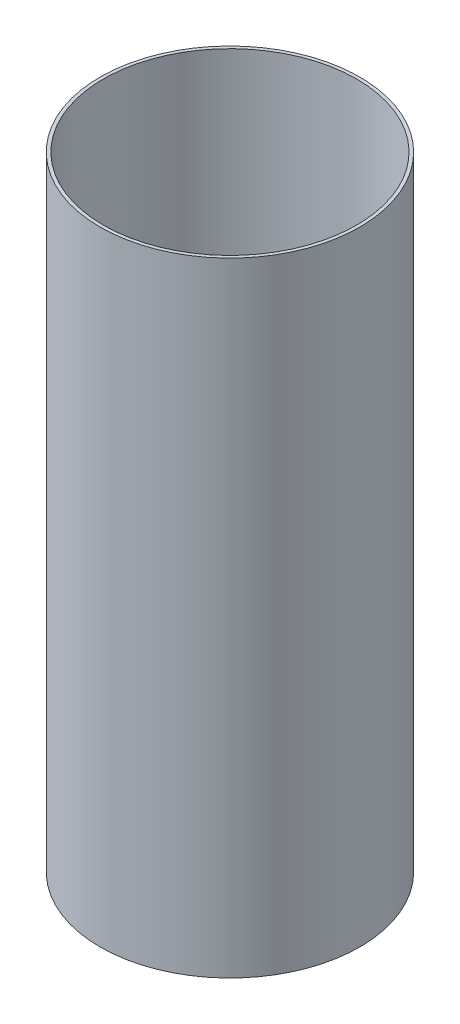
from build123d import *

# Parameters (mm, degrees)
BOSS_EXTRUDE1_DEPTH      = 304.8
BOSS_EXTRUDE1_DEPTH_BACK = 304.8
SKETCH1_R                = 127
SKETCH1_R_2              = 123.825


with BuildPart() as part:
    # Sketch1 → Boss-Extrude1 (new, two sides: drawn at the far end of the back side and taken through both)
    with BuildSketch(Plane(origin=(0, 0, 0), x_dir=(1, 0, 0), z_dir=(0, 1, 0)).offset(-BOSS_EXTRUDE1_DEPTH_BACK)):
        Circle(SKETCH1_R)
        Circle(SKETCH1_R_2, mode=Mode.SUBTRACT)
    extrude(amount=BOSS_EXTRUDE1_DEPTH + BOSS_EXTRUDE1_DEPTH_BACK)


solid = part.part
